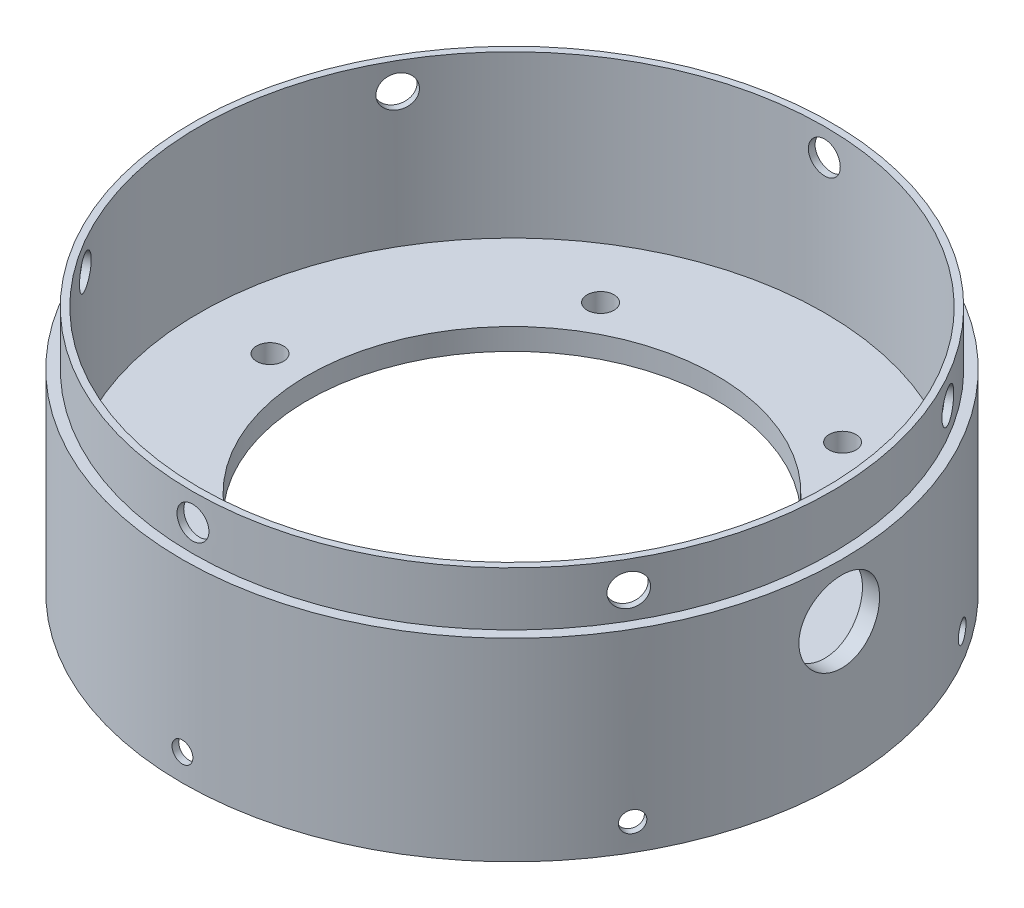
from build123d import *

# Parameters (mm, degrees)
SKETCH3_R                             = 77.8637
BOSS_EXTRUDE1_DEPTH                   = 2.54
BOSS_EXTRUDE1_DEPTH_BACK              = 2.54
SKETCH4_R                             = 77.8637
SKETCH4_R_2                           = 73.8505
BOSS_EXTRUDE3_DEPTH                   = 25.4
SKETCH5_R                             = 75.438
SKETCH5_R_2                           = 73.8505
BOSS_EXTRUDE4_DEPTH                   = 12.7
F_19_64_0_29688_DIAMETER_HOLE1_REACH  = 177.843
F_19_64_0_29688_DIAMETER_HOLE1_BORE_R = 3.770376
SKETCH7_R                             = 77.8637
SKETCH7_R_2                           = 73.8505
BOSS_EXTRUDE5_DEPTH                   = 2.54
SKETCH8_R                             = 77.8637
SKETCH8_R_2                           = 76.2889
BOSS_EXTRUDE6_DEPTH                   = 12.7
F_10_0_1935_DIAMETER_HOLE1_REACH      = 183.728
F_10_0_1935_DIAMETER_HOLE1_BORE_R     = 2.45745
F_1_4_0_25_DIAMETER_HOLE3_D           = 6.35
CIRPATTERN2_COUNT                     = 6
CUT_EXTRUDE2_REACH                    = 118.521
SKETCH10_R                            = 48.26
F_3_4_0_75_DIAMETER_HOLE1_REACH       = 179.212
F_3_4_0_75_DIAMETER_HOLE1_BORE_R      = 9.525


with BuildPart() as part:
    # Sketch3 → Boss-Extrude1 (new, two sides)
    with BuildSketch(Plane(origin=(0, 0, 0), x_dir=(1, 0, 0), z_dir=(0, 1, 0))) as boss_extrude1_sk:
        with Locations(Location((0, 0, 0), (0, 0, 270))):
            Circle(SKETCH3_R)
    extrude(amount=BOSS_EXTRUDE1_DEPTH)
    extrude(boss_extrude1_sk.sketch, amount=-BOSS_EXTRUDE1_DEPTH_BACK)

    # Sketch4 → Boss-Extrude3 (add)
    with BuildSketch(Plane(origin=(0, 2.54, 0), x_dir=(1, 0, 0), z_dir=(0, 1, 0))):
        with Locations(Location((0, 0, 0), (0, 0, 270))):
            Circle(SKETCH4_R)
        with Locations(Location((0, 0, 0), (0, 0, 270))):
            Circle(SKETCH4_R_2, mode=Mode.SUBTRACT)
    extrude(amount=BOSS_EXTRUDE3_DEPTH)

    # Sketch5 → Boss-Extrude4 (add)
    with BuildSketch(Plane(origin=(0, 27.94, 0), x_dir=(1, 0, 0), z_dir=(0, 1, 0))):
        with Locations(Location((0, 0, 0), (0, 0, 270))):
            Circle(SKETCH5_R)
        with Locations(Location((0, 0, 0), (0, 0, 270))):
            Circle(SKETCH5_R_2, mode=Mode.SUBTRACT)
    extrude(amount=BOSS_EXTRUDE4_DEPTH)

    # 19_64 _0.29688_ Diameter Hole1 bore (on position points) → 19_64 _0.29688_ Diameter Hole1 (cut, up to next)
    with BuildSketch(Plane(origin=(0, 34.29, 75.438), x_dir=(1, 0, 0), z_dir=(0, 0, 1)), mode=Mode.PRIVATE) as f_19_64_0_29688_diameter_hole1_sk1:
        Circle(F_19_64_0_29688_DIAMETER_HOLE1_BORE_R)
    f_19_64_0_29688_diameter_hole1_tool1 = extrude(f_19_64_0_29688_diameter_hole1_sk1.sketch, amount=-F_19_64_0_29688_DIAMETER_HOLE1_REACH, mode=Mode.PRIVATE) & part.part
    f_19_64_0_29688_diameter_hole1 = f_19_64_0_29688_diameter_hole1_tool1.solids().sort_by_distance((0, 34.29, 75.438))[0]
    add(f_19_64_0_29688_diameter_hole1, mode=Mode.SUBTRACT)

    # Sketch7 → Boss-Extrude5 (add)
    with BuildSketch(Plane.XZ.offset(2.54)):
        with Locations(Location((0, 0, 0), (0, 0, 90))):
            Circle(SKETCH7_R)
        with Locations(Location((0, 0, 0), (0, 0, 90))):
            Circle(SKETCH7_R_2, mode=Mode.SUBTRACT)
    extrude(amount=BOSS_EXTRUDE5_DEPTH)

    # Sketch8 → Boss-Extrude6 (add)
    with BuildSketch(Plane.XZ.offset(5.08)):
        with Locations(Location((0, 0, 0), (0, 0, 90))):
            Circle(SKETCH8_R)
        with Locations(Location((0, 0, 0), (0, 0, 270))):
            Circle(SKETCH8_R_2, mode=Mode.SUBTRACT)
    extrude(amount=BOSS_EXTRUDE6_DEPTH)

    # 10 _0.1935_ Diameter Hole1 bore (on position points) → 10 _0.1935_ Diameter Hole1 (cut, up to next)
    with BuildSketch(Plane(origin=(0, -11.43, 77.8637), x_dir=(1, 0, 0), z_dir=(0, 0, 1)), mode=Mode.PRIVATE) as f_10_0_1935_diameter_hole1_sk1:
        Circle(F_10_0_1935_DIAMETER_HOLE1_BORE_R)
    f_10_0_1935_diameter_hole1_tool1 = extrude(f_10_0_1935_diameter_hole1_sk1.sketch, amount=-F_10_0_1935_DIAMETER_HOLE1_REACH, mode=Mode.PRIVATE) & part.part
    f_10_0_1935_diameter_hole1 = f_10_0_1935_diameter_hole1_tool1.solids().sort_by_distance((0, -11.43, 77.8637))[0]
    add(f_10_0_1935_diameter_hole1, mode=Mode.SUBTRACT)

    # 1_4 _0.25_ Diameter Hole3 (through all)
    with Locations(Plane(origin=(0, 2.54, 0), x_dir=(1, 0, 0), z_dir=(0, 1, 0))):
        with Locations((-28.575, -49.493351826)):
            f_1_4_0_25_diameter_hole3 = Hole(F_1_4_0_25_DIAMETER_HOLE3_D / 2)

    # CirPattern2: 19_64 _0.29688_ Diameter Hole1, 10 _0.1935_ Diameter Hole1, 1_4 _0.25_ Diameter Hole3 ×6 about axis
    cirpattern2_axis = Axis((0, 0, 0), (0, 1, 0))
    add([f_19_64_0_29688_diameter_hole1.rotate(cirpattern2_axis, i * 360 / CIRPATTERN2_COUNT) for i in range(1, CIRPATTERN2_COUNT)], mode=Mode.SUBTRACT)
    add([f_10_0_1935_diameter_hole1.rotate(cirpattern2_axis, i * 360 / CIRPATTERN2_COUNT) for i in range(1, CIRPATTERN2_COUNT)], mode=Mode.SUBTRACT)
    add([f_1_4_0_25_diameter_hole3.rotate(cirpattern2_axis, i * 360 / CIRPATTERN2_COUNT) for i in range(1, CIRPATTERN2_COUNT)], mode=Mode.SUBTRACT)

    # Sketch10 → Cut-Extrude2 (cut, up to next)
    with BuildSketch(Plane(origin=(0, 2.54, 0), x_dir=(1, 0, 0), z_dir=(0, 1, 0)), mode=Mode.PRIVATE) as cut_extrude2_sk1:
        with Locations(Location((0, 0, 0), (0, 0, 270))):
            Circle(SKETCH10_R)
    cut_extrude2_tool1 = extrude(cut_extrude2_sk1.sketch, amount=-CUT_EXTRUDE2_REACH, mode=Mode.PRIVATE) & part.part
    add(cut_extrude2_tool1.solids().sort_by_distance((0, 2.54, 0))[0], mode=Mode.SUBTRACT)

    # 3_4 _0.75_ Diameter Hole1 bore (on position points) → 3_4 _0.75_ Diameter Hole1 (cut, up to next)
    with BuildSketch(Plane(origin=(77.8637, 15.24, 0), x_dir=(0, 0, 1), z_dir=(1, 0, 0)), mode=Mode.PRIVATE) as f_3_4_0_75_diameter_hole1_sk1:
        Circle(F_3_4_0_75_DIAMETER_HOLE1_BORE_R)
    f_3_4_0_75_diameter_hole1_tool1 = extrude(f_3_4_0_75_diameter_hole1_sk1.sketch, amount=-F_3_4_0_75_DIAMETER_HOLE1_REACH, mode=Mode.PRIVATE) & part.part
    add(f_3_4_0_75_diameter_hole1_tool1.solids().sort_by_distance((77.8637, 15.24, 0))[0], mode=Mode.SUBTRACT)


solid = part.part
